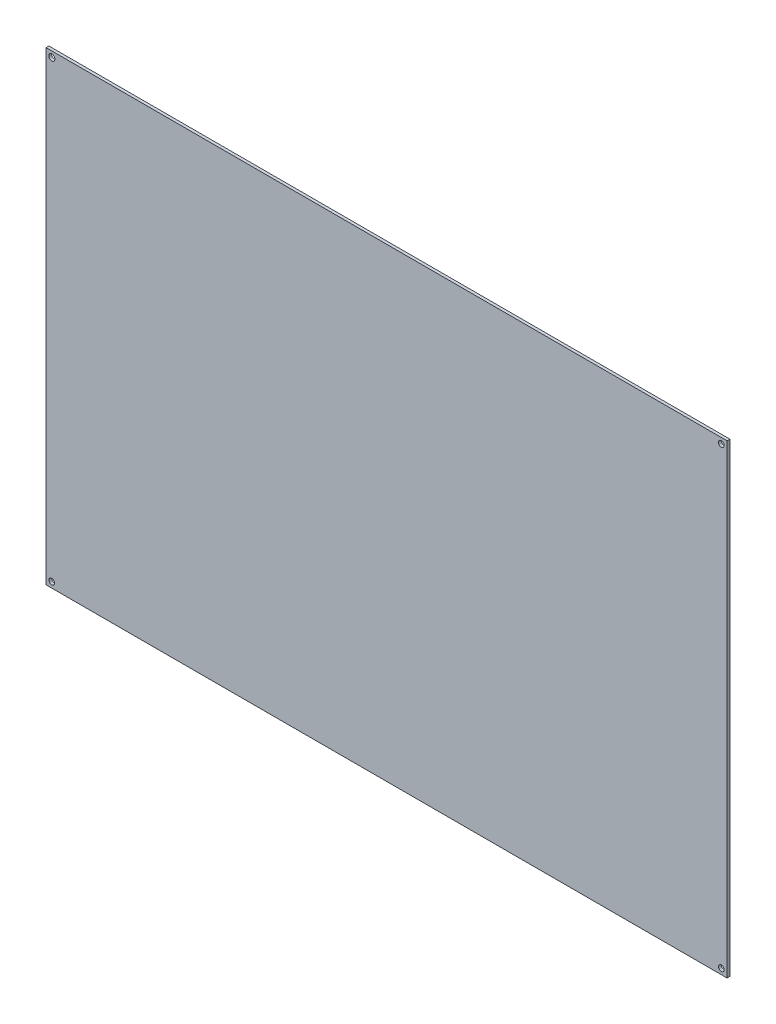
from build123d import *

# Parameters (mm, degrees)
SKETCH1_W           = 762
SKETCH1_H           = 520.7
BOSS_EXTRUDE1_DEPTH = 3.175
SKETCH2_R           = 3.429
SKETCH2_R_2         = 3.175
CUT_EXTRUDE1_DEPTH  = 6.35


with BuildPart() as part:
    # Sketch1 → Boss-Extrude1 (new body)
    with BuildSketch(Plane.XY):
        Rectangle(SKETCH1_W, SKETCH1_H)
    extrude(amount=BOSS_EXTRUDE1_DEPTH)

    # Sketch2 → Cut-Extrude1 (cut)
    with BuildSketch(Plane.XY.offset(3.175)):
        with Locations((-374.65, 254)):
            Circle(SKETCH2_R)
        with Locations((374.65, 254)):
            Circle(SKETCH2_R_2)
        with Locations((-374.65, -254)):
            Circle(SKETCH2_R_2)
        with Locations((374.65, -254)):
            Circle(SKETCH2_R_2)
    extrude(amount=-CUT_EXTRUDE1_DEPTH, mode=Mode.SUBTRACT)


solid = part.part
